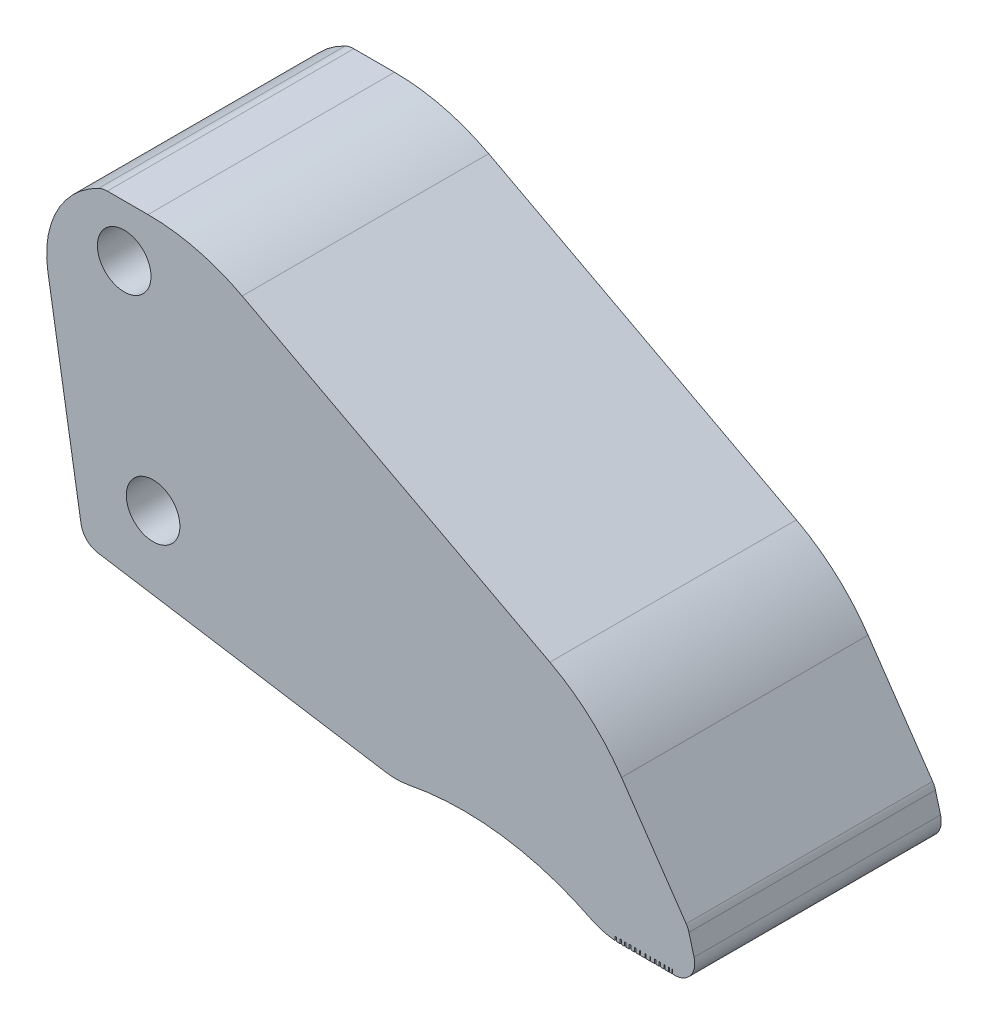
from build123d import *

# Parameters (mm, degrees)
SKETCH1_R           = 4
SKETCH1_W           = 0.443674292
SKETCH1_H           = 0.606573965
SKETCH1_W_2         = 0.441272097
SKETCH1_W_3         = 0.539332563
SKETCH1_W_4         = 0.547504268
SKETCH1_W_5         = 0.686423262
SKETCH1_W_6         = 0.607984695
SKETCH1_W_7         = 0.472854348
SKETCH1_W_8         = 0.501804613
SKETCH1_W_9         = 0.559705146
SKETCH1_W_10        = 0.321886919
SKETCH1_W_11        = 0.335329484
BOSS_EXTRUDE1_DEPTH = 36.8
SKETCH2_W           = 17.119195375
SKETCH2_H           = 26.8
CUT_EXTRUDE1_DEPTH  = 45


with BuildPart() as part:
    # Sketch1 → Boss-Extrude1 (new body)
    with BuildSketch(Plane.XY):
        with BuildLine():
            ThreePointArc((-2.487228681, 2.47588145), (-1.643417841, 0.836304882), (0, 0))
            Line((0, 0), (42.98, -6.863043607))
            ThreePointArc((42.98, -6.863043607), (44.726436776, -6.986706153), (46.46767433, -6.803879411))
            ThreePointArc((46.46767433, -6.803879411), (60.333502735, -6.411334854), (73.586869705, -10.505666612))
            ThreePointArc((73.586869705, -10.505666612), (75.109024375, -11.116277731), (76.710514264, -11.469874834))
            Line((76.710514264, -11.469874834), (76.710514264, -10.954571675))
            Line((76.710514264, -10.954571675), (77.19406036, -10.954571675))
            Line((77.19406036, -10.954571675), (77.47538128, -10.954571675))
            Line((77.47538128, -10.954571675), (77.981998439, -10.954571675))
            Line((77.981998439, -10.954571675), (78.200260874, -10.954571675))
            Line((78.200260874, -10.954571675), (78.643935166, -10.954571675))
            Line((78.643935166, -10.954571675), (78.872742919, -10.954571675))
            Line((78.872742919, -10.954571675), (79.314015016, -10.954571675))
            Line((79.314015016, -10.954571675), (79.591853003, -10.954571675))
            Line((79.591853003, -10.954571675), (80.131185566, -10.954571675))
            Line((80.131185566, -10.954571675), (80.343649909, -10.954571675))
            Line((80.343649909, -10.954571675), (80.891154177, -10.954571675))
            Line((80.891154177, -10.954571675), (81.013729759, -10.954571675))
            Line((81.013729759, -10.954571675), (81.700153021, -10.954571675))
            Line((81.700153021, -10.954571675), (81.871758836, -10.954571675))
            Line((81.871758836, -10.954571675), (82.419263104, -10.954571675))
            Line((82.419263104, -10.954571675), (82.535057995, -10.954571675))
            Line((82.535057995, -10.954571675), (83.14304269, -10.954571675))
            Line((83.14304269, -10.954571675), (83.326547781, -10.954571675))
            Line((83.326547781, -10.954571675), (83.799402129, -10.954571675))
            Line((83.799402129, -10.954571675), (84.002053992, -10.954571675))
            Line((84.002053992, -10.954571675), (84.503858605, -10.954571675))
            Line((84.503858605, -10.954571675), (84.677560202, -10.954571675))
            Line((84.677560202, -10.954571675), (85.237265348, -10.954571675))
            Line((85.237265348, -10.954571675), (85.365140123, -10.954571675))
            Line((85.365140123, -10.954571675), (85.700469607, -10.954571675))
            Line((85.700469607, -10.954571675), (85.806620583, -10.954571675))
            Line((85.806620583, -10.954571675), (86.128507502, -10.954571675))
            Line((86.128507502, -10.954571675), (86.128507502, -11.56114564))
            ThreePointArc((86.128507502, -11.56114564), (88.510189101, -10.385314701), (89.024900759, -7.779540815))
            Line((89.024900759, -7.779540815), (88.261533379, -4.950730067))
            ThreePointArc((88.261533379, -4.950730067), (88.089699744, -4.476637927), (87.840885143, -4.038024828))
            Line((87.840885143, -4.038024828), (78.200260874, 10.048964336))
            ThreePointArc((78.200260874, 10.048964336), (73.431103782, 15.477008911), (67.502436306, 19.607315102))
            Line((67.502436306, 19.607315102), (21.566587187, 43.977332864))
            ThreePointArc((21.566587187, 43.977332864), (14.751147415, 46.588108627), (7.506961555, 47.47588145))
            Line((7.506961555, 47.47588145), (1.426961555, 47.47588145))
            ThreePointArc((1.426961555, 47.47588145), (0.761339604, 47.401107495), (0.128898443, 47.180513062))
            ThreePointArc((0.128898443, 47.180513062), (-1.383603673, 46.332621816), (-2.77660534, 45.300086793))
            ThreePointArc((-2.77660534, 45.300086793), (-6.782062218, 39.585860112), (-7.445250004, 32.639188007))
            Line((-7.445250004, 32.639188007), (-2.487228681, 2.47588145))
        make_face()
        with Locations((8.267526818, 9.561727541)):
            Circle(SKETCH1_R, mode=Mode.SUBTRACT)
        with Locations((3.948380067, 39.69588145)):
            Circle(SKETCH1_R, mode=Mode.SUBTRACT)
        with BuildLine():
            Line((76.710514264, -10.954571675), (76.710514264, -11.469874834))
            ThreePointArc((76.710514264, -11.469874834), (76.951959843, -11.499734689), (77.19406036, -11.523712134))
            Line((77.19406036, -11.523712134), (77.19406036, -10.954571675))
            Line((77.19406036, -10.954571675), (76.710514264, -10.954571675))
        make_face()
        with BuildLine():
            Line((77.47538128, -10.954571675), (77.47538128, -11.544129353))
            ThreePointArc((77.47538128, -11.544129353), (77.728583879, -11.555701678), (77.981998439, -11.560852954))
            Line((77.981998439, -11.560852954), (77.981998439, -10.954571675))
            Line((77.981998439, -10.954571675), (77.47538128, -10.954571675))
        make_face()
        with Locations((78.42209802, -11.257858658)):
            Rectangle(SKETCH1_W, SKETCH1_H)
        with Locations((79.093378968, -11.257858658)):
            Rectangle(SKETCH1_W_2, SKETCH1_H)
        with Locations((79.861519285, -11.257858658)):
            Rectangle(SKETCH1_W_3, SKETCH1_H)
        with Locations((80.617402043, -11.257858658)):
            Rectangle(SKETCH1_W_4, SKETCH1_H)
        with Locations((81.35694139, -11.257858658)):
            Rectangle(SKETCH1_W_5, SKETCH1_H)
        with Locations((82.14551097, -11.257858658)):
            Rectangle(SKETCH1_W_4, SKETCH1_H)
        with Locations((82.839050343, -11.257858658)):
            Rectangle(SKETCH1_W_6, SKETCH1_H)
        with Locations((83.562974955, -11.257858658)):
            Rectangle(SKETCH1_W_7, SKETCH1_H)
        with Locations((84.252956299, -11.257858658)):
            Rectangle(SKETCH1_W_8, SKETCH1_H)
        with Locations((84.957412775, -11.257858658)):
            Rectangle(SKETCH1_W_9, SKETCH1_H)
        with Locations((85.967564043, -11.257858658)):
            Rectangle(SKETCH1_W_10, SKETCH1_H)
        with Locations((85.532804865, -11.257858658)):
            Rectangle(SKETCH1_W_11, SKETCH1_H)
    extrude(amount=BOSS_EXTRUDE1_DEPTH)

    # Sketch2 → Cut-Extrude1 (cut)
    with BuildSketch(Plane(origin=(0, -40, 0), x_dir=(1, 0, 0), z_dir=(0, 1, 0))):
        with Locations((60.027272017, -18.4)):
            Rectangle(SKETCH2_W, SKETCH2_H)
    extrude(amount=CUT_EXTRUDE1_DEPTH, mode=Mode.SUBTRACT)


solid = part.part
